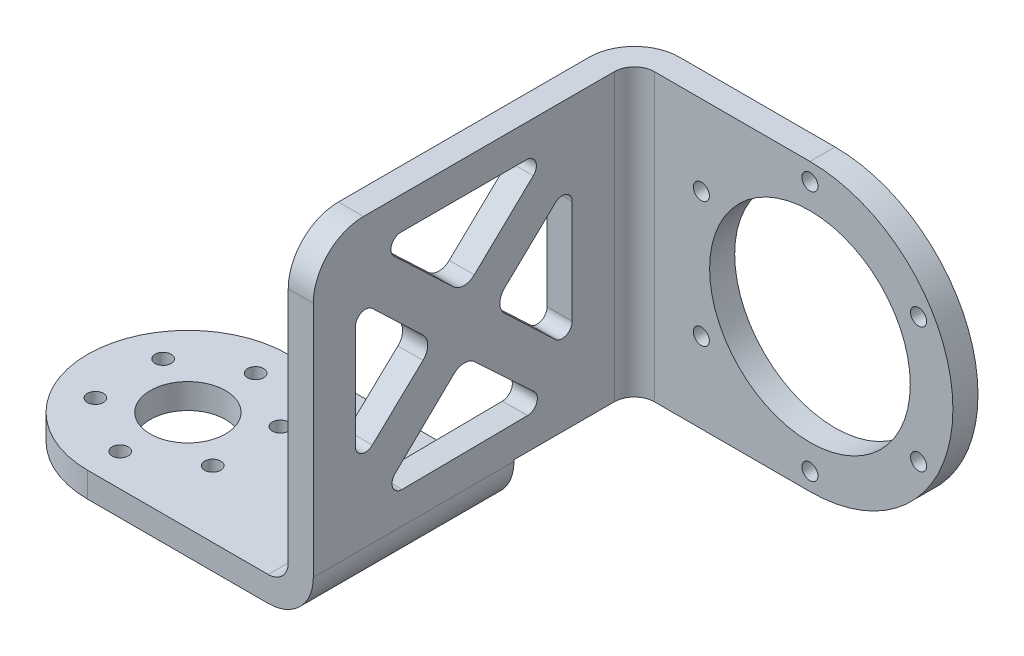
from build123d import *

# Parameters (mm, degrees)
EXTRUDE_1_DEPTH     = 5
SKETCH_3_R          = 1.6
CUT_EXTRUDE_1_DEPTH = 11
EXTRUDE_3_DEPTH     = 5
EXTRUDE_4_DEPTH     = 5
SKETCH_25_R         = 20
CUT_EXTRUDE_2_DEPTH = 5
FILLET_1_R          = 4
FILLET_4_R          = 9
SKETCH_19_R         = 7.5
CUT_EXTRUDE_3_DEPTH = 5
SKETCH_26_R         = 1.6
CUT_EXTRUDE_4_DEPTH = 5
FILLET_5_R          = 10
CUT_EXTRUDE_5_DEPTH = 5
FILLET_10_R         = 2
FILLET_11_R         = 3


with BuildPart() as part:
    # 草图1 → 凸台-拉伸1 (new body)
    with BuildSketch(Plane(origin=(0, 0, 0), x_dir=(1, 0, 0), z_dir=(0, 1, 0))):
        with BuildLine():
            Line((45, 20), (0, 20))
            ThreePointArc((0, 20), (-20, 0), (0, -20))
            Line((0, -20), (45, -20))
            Line((45, -20), (45, 20))
        make_face()
    extrude(amount=EXTRUDE_1_DEPTH)

    # 草图3 → 切除-拉伸1 (cut)
    with BuildSketch(Plane(origin=(0, 5, 0), x_dir=(1, 0, 0), z_dir=(0, 1, 0))):
        with Locations((0, 13.5)):
            Circle(SKETCH_3_R)
        with Locations((11.691342951, 6.75)):
            Circle(SKETCH_3_R)
        with Locations((11.691342951, -6.75)):
            Circle(SKETCH_3_R)
        with Locations((0, -13.5)):
            Circle(SKETCH_3_R)
        with Locations((-11.691342951, -6.75)):
            Circle(SKETCH_3_R)
        with Locations((-11.691342951, 6.75)):
            Circle(SKETCH_3_R)
    extrude(amount=-CUT_EXTRUDE_1_DEPTH, mode=Mode.SUBTRACT)

    # 草图22 → 凸台-拉伸3 (add)
    with BuildSketch(Plane(origin=(45, 0, 0), x_dir=(0, 0, -1), z_dir=(1, 0, 0))):
        Polygon((-20, 5), (20, 5), (20, 9.3), (44, 9.3), (44, 66.3), (-20, 66.3), align=None)
    extrude(amount=-EXTRUDE_3_DEPTH)

    # 草图24 → 凸台-拉伸4 (add)
    with BuildSketch(Plane(origin=(0, 0, -44), x_dir=(-1, 0, 0), z_dir=(0, 0, -1))):
        with BuildLine():
            Line((-40, 9.3), (-80, 9.3))
            ThreePointArc((-80, 9.3), (-108.5, 37.8), (-80, 66.3))
            Line((-80, 66.3), (-40, 66.3))
            Line((-40, 66.3), (-40, 9.3))
        make_face()
    extrude(amount=EXTRUDE_4_DEPTH)

    # 草图25 → 切除-拉伸2 (cut)
    with BuildSketch(Plane(origin=(0, 0, -49), x_dir=(-1, 0, 0), z_dir=(0, 0, -1))):
        with Locations((-80, 37.8)):
            Circle(SKETCH_25_R)
    extrude(amount=-CUT_EXTRUDE_2_DEPTH, mode=Mode.SUBTRACT)

    # 圆角1
    fillet_1_edges = [part.edges().sort_by_distance(p)[0] for p in [
        (40, 5, 0),
        (45, 37.8, -44),
    ]]
    fillet(fillet_1_edges, radius=FILLET_1_R)

    # 圆角4
    fillet_4_edges = [part.edges().sort_by_distance(p)[0] for p in [
        (45, 0, 0),
        (40, 37.8, -49),
    ]]
    fillet(fillet_4_edges, radius=FILLET_4_R)

    # 草图19 → 切除-拉伸3 (cut)
    with BuildSketch(Plane.XZ):
        Circle(SKETCH_19_R)
    extrude(amount=-CUT_EXTRUDE_3_DEPTH, mode=Mode.SUBTRACT)

    # 草图26 → 切除-拉伸4 (cut)
    with BuildSketch(Plane.XY.offset(-44)):
        with Locations((101.650635095, 50.3)):
            Circle(SKETCH_26_R)
        with Locations((101.650635095, 25.3)):
            Circle(SKETCH_26_R)
        with Locations((80, 12.8)):
            Circle(SKETCH_26_R)
        with Locations((58.349364905, 25.3)):
            Circle(SKETCH_26_R)
        with Locations((58.349364905, 50.3)):
            Circle(SKETCH_26_R)
        with Locations((80, 62.8)):
            Circle(SKETCH_26_R)
    extrude(amount=-CUT_EXTRUDE_4_DEPTH, mode=Mode.SUBTRACT)

    # 圆角5
    fillet_5_edges = [part.edges().sort_by_distance(p)[0] for p in [
        (42.5, 66.3, 20),
    ]]
    fillet(fillet_5_edges, radius=FILLET_5_R)

    # 草图27 → 切除-拉伸5 (cut)
    with BuildSketch(Plane(origin=(45, 0, 0), x_dir=(0, 0, -1), z_dir=(1, 0, 0))):
        Polygon((10.027417726, 43.207223614), (-7.542180321, 59.853257478), (27.457819679, 59.853257478), align=None)
        Polygon((15.84211595, 37.698181047), (31.611388693, 52.757836516), (31.611388693, 22.757836516), align=None)
        Polygon((-7.31927621, 15.272435239), (27.678973834, 15.622426489), (10.082987202, 32.093328411), align=None)
        Polygon((-11.611388693, 52.757836516), (-11.611388693, 22.757836516), (4.15788405, 37.698181047), align=None)
    extrude(amount=-CUT_EXTRUDE_5_DEPTH, mode=Mode.SUBTRACT)

    # 圆角10
    fillet_10_edges = [part.edges().sort_by_distance(p)[0] for p in [
        (42.5, 15.272435239, 7.31927621),
        (42.5, 15.622426489, -27.678973834),
        (42.5, 22.757836516, -31.611388693),
        (42.5, 52.757836516, -31.611388693),
        (42.5, 52.757836516, 11.611388693),
        (42.5, 22.757836516, 11.611388693),
        (42.5, 59.853257478, -27.457819679),
        (42.5, 59.853257478, 7.542180321),
    ]]
    fillet(fillet_10_edges, radius=FILLET_10_R)

    # 圆角11
    fillet_11_edges = [part.edges().sort_by_distance(p)[0] for p in [
        (42.5, 32.093328411, -10.082987202),
        (42.5, 37.698181047, -15.84211595),
        (42.5, 37.698181047, -4.15788405),
        (42.5, 43.207223614, -10.027417726),
    ]]
    fillet(fillet_11_edges, radius=FILLET_11_R)


solid = part.part
